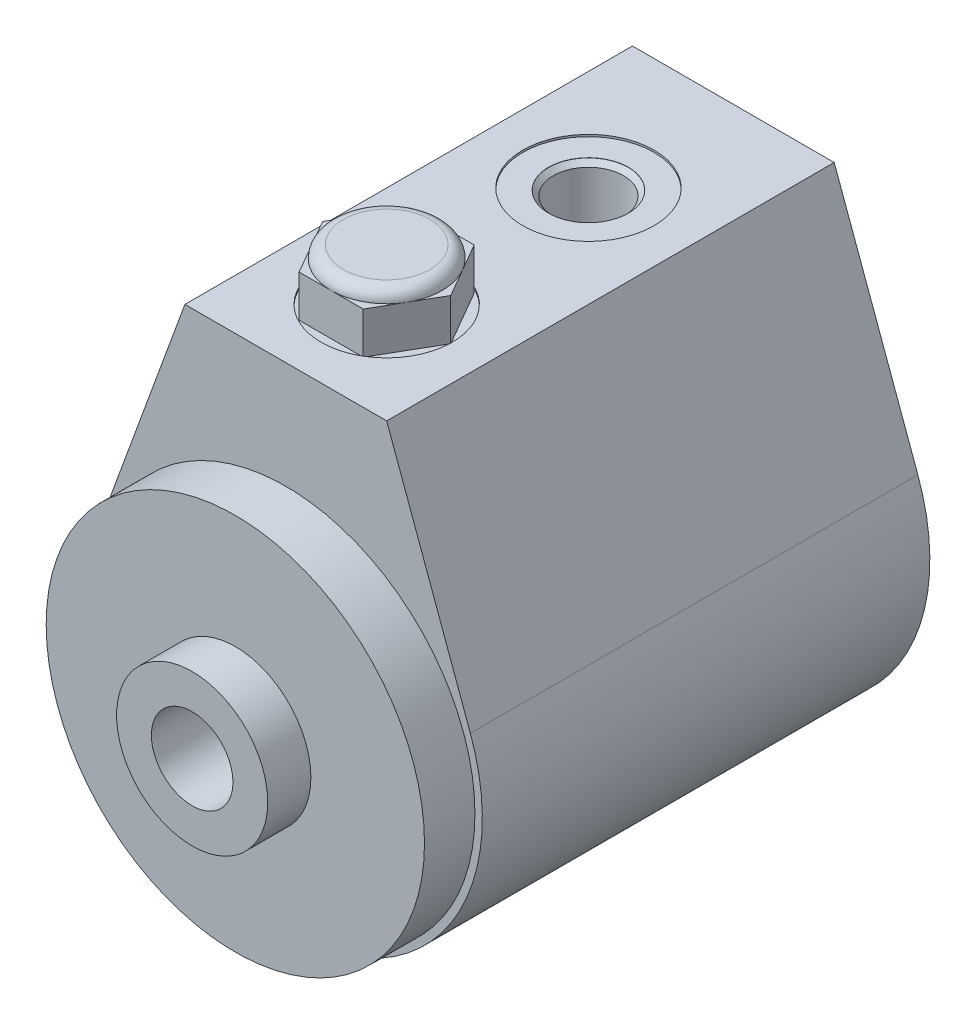
from build123d import *

# Parameters (mm, degrees)
EXTRUDE1_DEPTH    = 56.3372
HOLE2_D           = 23.876
HOLE2_DEPTH       = 6.35
SKETCH6_W         = 9.5123
SKETCH6_H         = 0.9398
HOLE3_D           = 6.7818
HOLE3_DEPTH       = 12.7
CIRPATTERN1_COUNT = 2
LPATTERN1_COUNT   = 2
LPATTERN1_PITCH   = 25.4
EXTRUDE2_DEPTH    = 6.78


with BuildPart() as part:
    # Sketch1 → Extrude1 (new body)
    with BuildSketch(Plane.XY.offset(56.3372)):
        with BuildLine():
            Line((23.233094839, 8.501241812), (12.7, 37.2872))
            Line((12.7, 37.2872), (-12.7, 37.2872))
            Line((-12.7, 37.2872), (-23.233094839, 8.501241812))
            ThreePointArc((-23.233094839, 8.501241812), (0, -24.7396), (23.233094839, 8.501241812))
        make_face()
    extrude(amount=-EXTRUDE1_DEPTH)

    # Hole2
    with Locations(Plane(origin=(0, 0, 0), x_dir=(-1, 0, 0), z_dir=(0, 0, -1))):
        with Locations((0, 0)):
            Hole(HOLE2_D / 2, depth=HOLE2_DEPTH)

    # Sketch7 → Revolve2 (revolve)
    with BuildSketch(Plane.XZ):
        Polygon((9.5123, 68.1228), (0, 68.1228), (0, 56.3372), (23.8125, 56.3372), (23.8125, 62.6872), (9.5123, 62.6872), align=None)
    revolve(axis=Axis((0, 0, 0), (0, 0, 1)))

    # Sketch6 → Revolve1 (revolve)
    with BuildSketch(Plane.XZ):
        with Locations((4.75615, 5.8801)):
            Rectangle(SKETCH6_W, SKETCH6_H)
    revolve(axis=Axis((0, 0, 0), (0, 0, 1)))

    # Sketch9 → Cut-Revolve1 (revolve, cut)
    with BuildSketch(Plane.XY.offset(18.2372), mode=Mode.PRIVATE) as cut_revolve1_sk:
        Polygon((-4.4196, 21.7932), (0, 21.7932), (0, 37.2872), (-8.255, 37.2872), (-8.255, 37.0332), (-5.0165, 37.0332), (-5.0165, 37.0078), (-4.4196, 36.4109), align=None)
    cut_revolve1 = revolve(cut_revolve1_sk.sketch.rotate(Axis((0, 37.2872, 18.2372), (0, -1, 0)), 90), axis=Axis((0, 37.2872, 18.2372), (0, -1, 0)), mode=Mode.SUBTRACT)  # turned: the seam where the file's is

    # Hole3
    with Locations(Plane(origin=(0, 0, 0), x_dir=(-1, 0, 0), z_dir=(0, 0, -1))):
        with Locations((-18.0086, 0)):
            hole3 = Hole(HOLE3_D / 2, depth=HOLE3_DEPTH)

    # CirPattern1: Hole3 ×2 about axis
    cirpattern1_axis = Axis((0, 0, 0), (0, 0, 1))
    for i in range(1, CIRPATTERN1_COUNT):
        add(hole3.rotate(cirpattern1_axis, i * 360 / CIRPATTERN1_COUNT), mode=Mode.SUBTRACT)

    # Sketch15 → Hole5 (revolve, cut)
    with BuildSketch(Plane(origin=(0, 0, 5.4102), x_dir=(0, 1, 0), z_dir=(1, 0, 0))):
        Polygon((0, 0), (0, 62.7126), (5.1308, 62.7126), (5.1308, 48.721128092), (6.7437, 47.752), (6.7437, 0), align=None)
    revolve(axis=Axis((0, 0, -0.719823899), (0, 0, 1)), mode=Mode.SUBTRACT)

    # LPattern1: Cut-Revolve1 ×2
    with Locations(*[(0, 0, i * LPATTERN1_PITCH) for i in range(1, LPATTERN1_COUNT)]):
        add(cut_revolve1, mode=Mode.SUBTRACT)

    # Sketch17 → Extrude2 (add)
    with BuildSketch(Plane(origin=(0, 37.0332, 0), x_dir=(1, 0, 0), z_dir=(0, 1, 0))):
        Polygon((8.065583261, -43.6372), (4.03279163, -36.6522), (-4.03279163, -36.6522), (-8.065583261, -43.6372), (-4.03279163, -50.6222), (4.03279163, -50.6222), align=None)
    extrude(amount=EXTRUDE2_DEPTH)

    # Sketch18 → Cut-Revolve2 (revolve, cut)
    with BuildSketch(Plane(origin=(0, 0, 0), x_dir=(0, 0, -1), z_dir=(1, 0, 0)), mode=Mode.PRIVATE) as cut_revolve2_sk:
        with BuildLine():
            Line((-49.0982, 43.8132), (-49.0982, 46.8132))
            Line((-49.0982, 46.8132), (-53.6222, 46.8132))
            Line((-53.6222, 46.8132), (-53.6222, 42.2892))
            Line((-53.6222, 42.2892), (-50.6222, 42.2892))
            ThreePointArc((-50.6222, 42.2892), (-50.175830735, 43.366830735), (-49.0982, 43.8132))
        make_face()
    revolve(cut_revolve2_sk.sketch.rotate(Axis((0, 21.7932, 43.6372), (0, 1, 0)), 180), axis=Axis((0, 21.7932, 43.6372), (0, 1, 0)), mode=Mode.SUBTRACT)  # turned: the seam where the file's is


solid = part.part
